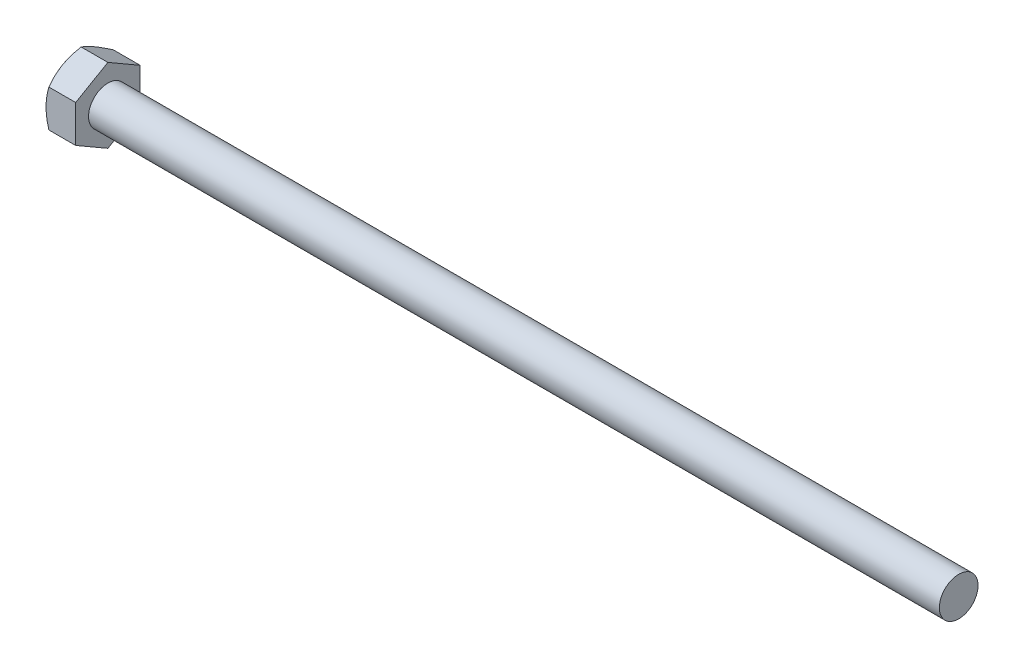
from build123d import *

# Parameters (mm, degrees)
SKETCH2_R     = 2.915704388
HEX_DIE_DEPTH = 2.3
SKETCH4_R     = 2.1875
INDENT_DEPTH  = 0.2875


with BuildPart() as part:
    # BodySke → Base-Revolve (revolve)
    with BuildSketch(Plane.XY):
        Polygon((2.3, 1.5), (2.3, 2.886836028), (0.223339885, 2.886836028), (0, 2.5), (0, 0), (68.3, 0), (68.3, 1.5), align=None)
    revolve(axis=Axis((-25.4, 0, 0), (1, 0, 0)))

    # Sketch2 → Hex-Die (cut)
    with BuildSketch(Plane(origin=(0, 0, 0), x_dir=(0, 0, -1), z_dir=(1, 0, 0))):
        Circle(SKETCH2_R)
        Polygon((-2.5, 1.443375679), (0, 2.886751359), (2.5, 1.443375679), (2.5, -1.443375679), (0, -2.886751359), (-2.5, -1.443375679), align=None, mode=Mode.SUBTRACT)
    extrude(amount=HEX_DIE_DEPTH, mode=Mode.SUBTRACT)

    # Sketch4 → Indent (cut)
    with BuildSketch(Plane(origin=(0, 0, 0), x_dir=(0, 0, -1), z_dir=(1, 0, 0))):
        Circle(SKETCH4_R)
    extrude(amount=INDENT_DEPTH, mode=Mode.SUBTRACT)


solid = part.part
